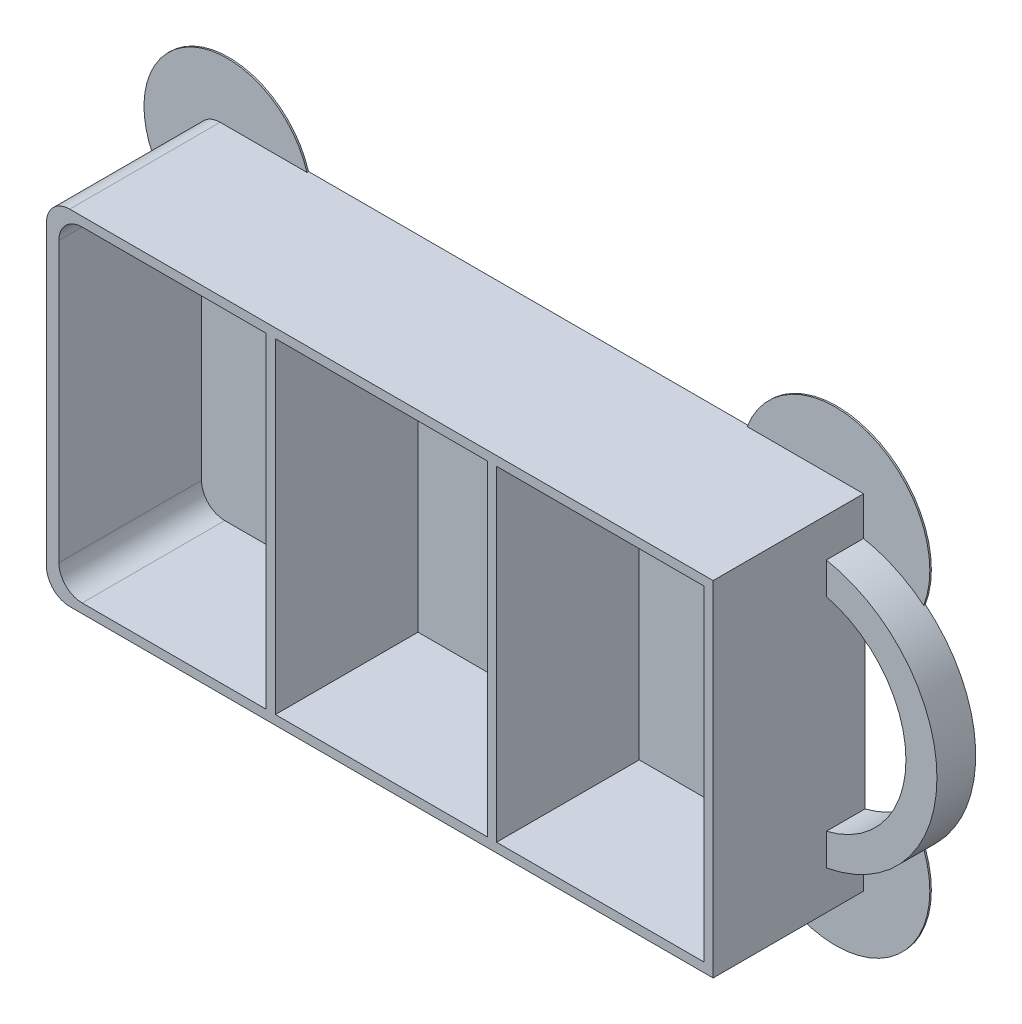
from build123d import *

# Parameters (mm, degrees)
SKETCH_1_W          = 86
SKETCH_1_H          = 44.4
EXTRUDE_1_DEPTH     = 19.6
EXTRUDE_2_DEPTH     = 5
SKETCH_3_W          = 26.733333333
SKETCH_3_H          = 42
SKETCH_3_W_2        = 27.333333334
CUT_EXTRUDE_1_DEPTH = 18.4
FILLET_1_R          = 3
EXTRUDE_3_DEPTH     = 0.2


with BuildPart() as part:
    # Эскиз1 → Бобышка-Вытянуть1 (new body)
    with BuildSketch(Plane.XY):
        Rectangle(SKETCH_1_W, SKETCH_1_H)
    extrude(amount=EXTRUDE_1_DEPTH)

    # Эскиз2 → Бобышка-Вытянуть2 (add)
    with BuildSketch(Plane.XY):
        with BuildLine():
            Line((43, 17.2), (43, 13.108775687))
            ThreePointArc((43, 13.108775687), (53.273546839, 0), (43, -13.108775687))
            Line((43, -13.108775687), (43, -17.2))
            ThreePointArc((43, -17.2), (57.273546839, 0), (43, 17.2))
        make_face()
    extrude(amount=EXTRUDE_2_DEPTH)

    # Эскиз3 → Вырез-Вытянуть1 (cut)
    with BuildSketch(Plane.XY.offset(19.6)):
        with Locations((-28.033333334, 0)):
            Rectangle(SKETCH_3_W, SKETCH_3_H)
        with Locations((0.2, 0)):
            Rectangle(SKETCH_3_W_2, SKETCH_3_H)
        with Locations((28.433333334, 0)):
            Rectangle(SKETCH_3_W, SKETCH_3_H)
    extrude(amount=-CUT_EXTRUDE_1_DEPTH, mode=Mode.SUBTRACT)

    # Скругление1
    fillet_1_edges = [part.edges().sort_by_distance(p)[0] for p in [
        (-41.4, 21, 10.4),
        (-41.4, -21, 10.4),
        (-43, -22.2, 9.8),
        (-43, 22.2, 9.8),
    ]]
    fillet(fillet_1_edges, radius=FILLET_1_R)

    # Эскиз4 → Бобышка-Вытянуть3 (add)
    with BuildSketch(Plane(origin=(0, 0, 0), x_dir=(-1, 0, 0), z_dir=(0, 0, -1))):
        with BuildLine():
            Line((-50.772048757, 13.611868188), (-27.989807175, 22.2))
            ThreePointArc((-27.989807175, 22.2), (-43.674993872, 29.297054885), (-50.772048757, 13.611868188))
        make_face()
        with BuildLine():
            Line((-50.772048757, -13.611868188), (-27.989807175, -22.2))
            ThreePointArc((-27.989807175, -22.2), (-43.674993872, -29.297054885), (-50.772048757, -13.611868188))
        make_face()
        with BuildLine():
            Line((43, 9.068731744), (28.793502644, 22.2))
            ThreePointArc((28.793502644, 22.2), (46.369205759, 26.964337461), (43, 9.068731744))
        make_face()
        with BuildLine():
            Line((43, -9.068731744), (28.793502644, -22.2))
            ThreePointArc((28.793502644, -22.2), (46.369205759, -26.964337461), (43, -9.068731744))
        make_face()
    extrude(amount=-EXTRUDE_3_DEPTH)


solid = part.part
